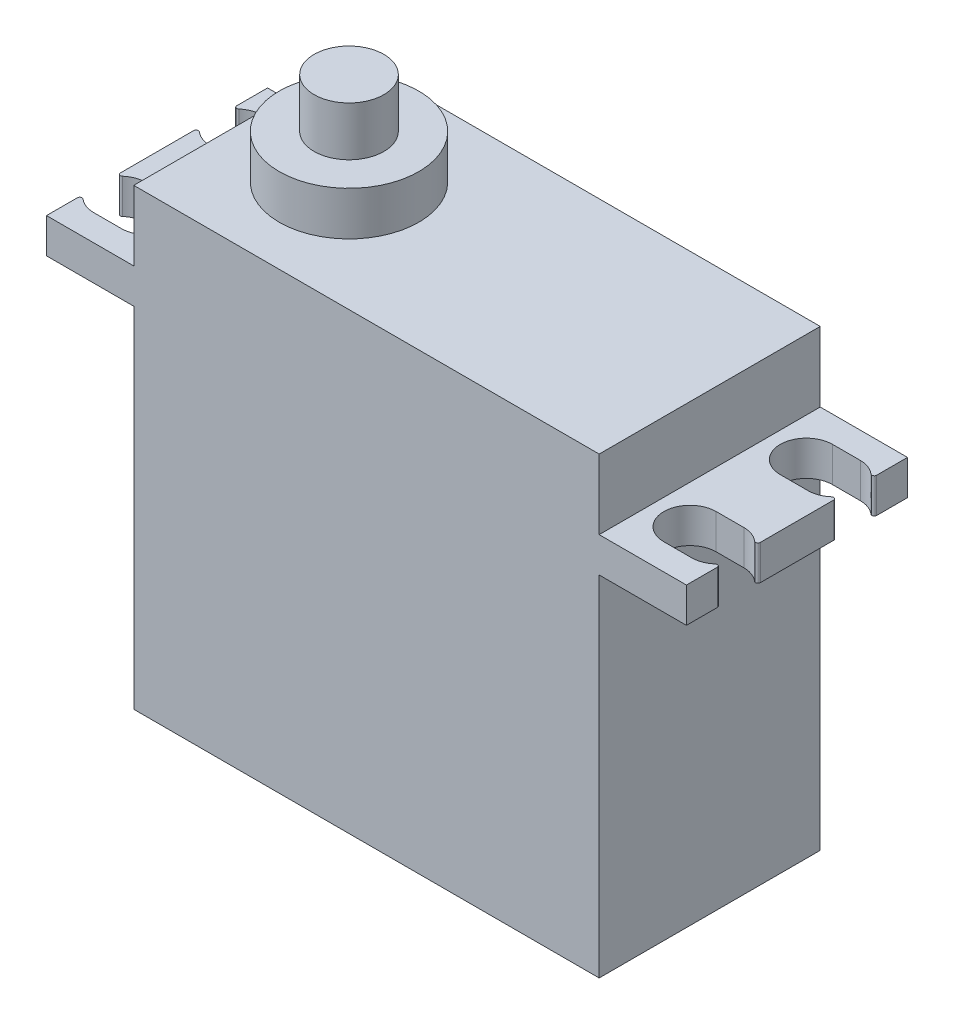
from build123d import *

# Parameters (mm, degrees)
SKETCH1_W                = 40
SKETCH1_H                = 19
BOSS_EXTRUDE1_DEPTH      = 39
SKETCH2_W                = 19
SKETCH2_H                = 3
BOSS_EXTRUDE2_DEPTH      = 7.5
BOSS_EXTRUDE2_DEPTH_BACK = 47.5
CUT_EXTRUDE1_DEPTH       = 3
FILLET1_R                = 0.2
SKETCH4_R                = 3
BOSS_EXTRUDE3_DEPTH      = 8
SKETCH6_R                = 6
BOSS_EXTRUDE4_DEPTH      = 3.77


with BuildPart() as part:
    # Sketch1 → Boss-Extrude1 (new body)
    with BuildSketch(Plane(origin=(0, 0, 0), x_dir=(1, 0, 0), z_dir=(0, 1, 0))):
        Rectangle(SKETCH1_W, SKETCH1_H)
    extrude(amount=BOSS_EXTRUDE1_DEPTH)

    # Sketch2 → Boss-Extrude2 (add, two sides)
    with BuildSketch(Plane(origin=(20, 0, 0), x_dir=(0, 0, -1), z_dir=(1, 0, 0))) as boss_extrude2_sk:
        with Locations((0, 31.5)):
            Rectangle(SKETCH2_W, SKETCH2_H)
    extrude(amount=BOSS_EXTRUDE2_DEPTH)
    extrude(boss_extrude2_sk.sketch, amount=-BOSS_EXTRUDE2_DEPTH_BACK)

    # Sketch3 → Cut-Extrude1 (cut)
    with BuildSketch(Plane(origin=(0, 33, 0), x_dir=(1, 0, 0), z_dir=(0, 1, 0))):
        with BuildLine():
            Line((-23.309672477, 2.75), (-25.690327523, 2.75))
            ThreePointArc((-25.690327523, 2.75), (-27.940327523, 5), (-25.690327523, 7.25))
            Line((-25.690327523, 7.25), (-23.309672477, 7.25))
            ThreePointArc((-23.309672477, 7.25), (-21.059672477, 5), (-23.309672477, 2.75))
        make_face()
        with BuildLine():
            Line((-23.309672477, -2.75), (-25.690327523, -2.75))
            ThreePointArc((-25.690327523, -2.75), (-27.940327523, -5), (-25.690327523, -7.25))
            Line((-25.690327523, -7.25), (-23.309672477, -7.25))
            ThreePointArc((-23.309672477, -7.25), (-21.059672477, -5), (-23.309672477, -2.75))
        make_face()
        with BuildLine():
            Line((23.309672477, -2.75), (25.690327523, -2.75))
            ThreePointArc((25.690327523, -2.75), (27.940327523, -5), (25.690327523, -7.25))
            Line((25.690327523, -7.25), (23.309672477, -7.25))
            ThreePointArc((23.309672477, -7.25), (21.059672477, -5), (23.309672477, -2.75))
        make_face()
        with BuildLine():
            Line((23.309672477, 2.75), (25.690327523, 2.75))
            ThreePointArc((25.690327523, 2.75), (27.940327523, 5), (25.690327523, 7.25))
            Line((25.690327523, 7.25), (23.309672477, 7.25))
            ThreePointArc((23.309672477, 7.25), (21.059672477, 5), (23.309672477, 2.75))
        make_face()
    extrude(amount=-CUT_EXTRUDE1_DEPTH, mode=Mode.SUBTRACT)

    # Fillet1
    fillet1_edges = [part.edges().sort_by_distance(p)[0] for p in [
        (27.5, 31.5, 6.337006181),
        (27.5, 31.5, 3.662993819),
        (27.5, 31.5, -3.662993819),
        (27.5, 31.5, -6.337006181),
        (-27.5, 31.5, 3.662993819),
        (-27.5, 31.5, 6.337006181),
        (-27.5, 31.5, -6.337006181),
        (-27.5, 31.5, -3.662993819),
    ]]
    fillet(fillet1_edges, radius=FILLET1_R)

    # Sketch4 → Boss-Extrude3 (add)
    with BuildSketch(Plane(origin=(0, 39, 0), x_dir=(1, 0, 0), z_dir=(0, 1, 0))):
        with Locations((-11, 0)):
            Circle(SKETCH4_R)
    extrude(amount=BOSS_EXTRUDE3_DEPTH)

    # Sketch6 → Boss-Extrude4 (add)
    with BuildSketch(Plane(origin=(0, 39, 0), x_dir=(1, 0, 0), z_dir=(0, 1, 0))):
        with Locations((-11, 0)):
            Circle(SKETCH6_R)
    extrude(amount=BOSS_EXTRUDE4_DEPTH)


solid = part.part
